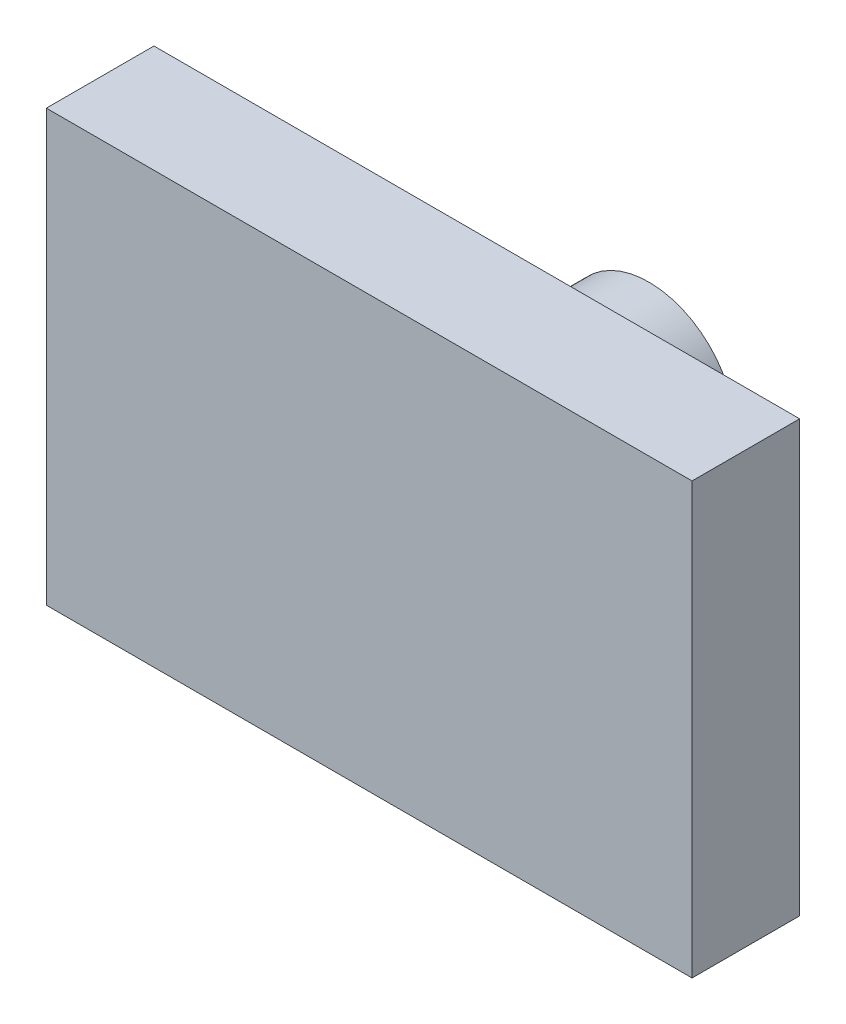
from build123d import *

# Parameters (mm, degrees)
CROQUIS1_W              = 30
CROQUIS1_H              = 20
SALIENTE_EXTRUIR1_DEPTH = 5
CROQUIS2_R              = 4
SALIENTE_EXTRUIR3_DEPTH = 8
CROQUIS3_R              = 2.1
CORTAR_EXTRUIR1_DEPTH   = 6.5


with BuildPart() as part:
    # Croquis1 → Saliente-Extruir1 (new body)
    with BuildSketch(Plane.XY):
        Rectangle(CROQUIS1_W, CROQUIS1_H)
    extrude(amount=SALIENTE_EXTRUIR1_DEPTH)

    # Croquis2 → Saliente-Extruir3 (add)
    with BuildSketch(Plane(origin=(0, 0, 0), x_dir=(-1, 0, 0), z_dir=(0, 0, -1))):
        Circle(CROQUIS2_R)
    extrude(amount=SALIENTE_EXTRUIR3_DEPTH)

    # Croquis3 → Cortar-Extruir1 (cut)
    with BuildSketch(Plane(origin=(0, 0, -8), x_dir=(-1, 0, 0), z_dir=(0, 0, -1))):
        Circle(CROQUIS3_R)
    extrude(amount=-CORTAR_EXTRUIR1_DEPTH, mode=Mode.SUBTRACT)


solid = part.part
